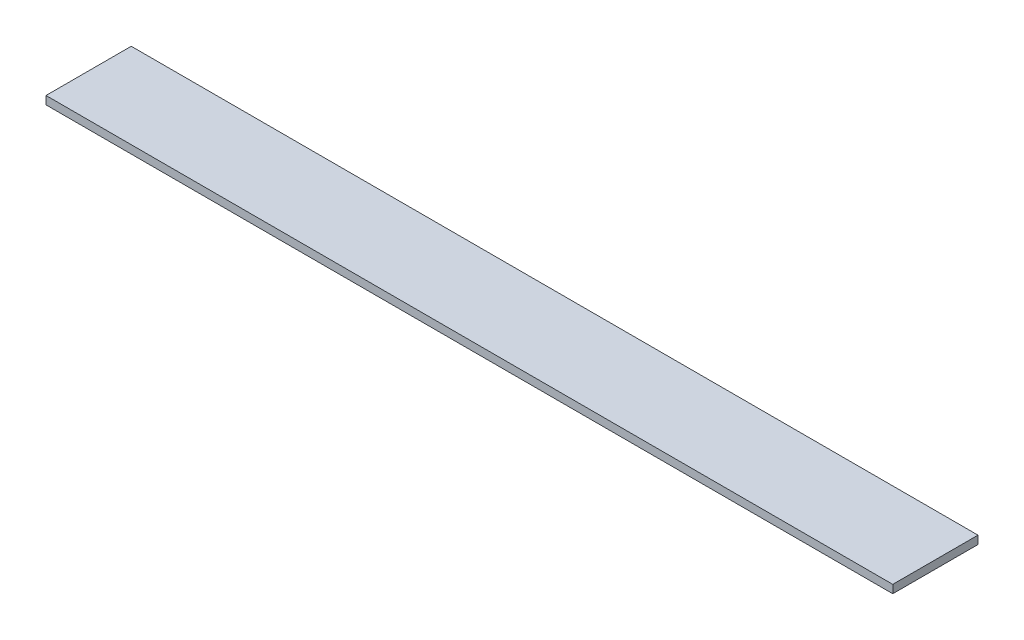
from build123d import *

# Parameters (mm, degrees)
SKETCH1_W           = 126.15926
SKETCH1_H           = 12.7
BOSS_EXTRUDE1_DEPTH = 1.21412


with BuildPart() as part:
    # Sketch1 → Boss-Extrude1 (new body)
    with BuildSketch(Plane(origin=(0, 0, 0), x_dir=(1, 0, 0), z_dir=(0, 1, 0))):
        Rectangle(SKETCH1_W, SKETCH1_H)
    extrude(amount=BOSS_EXTRUDE1_DEPTH)


solid = part.part
